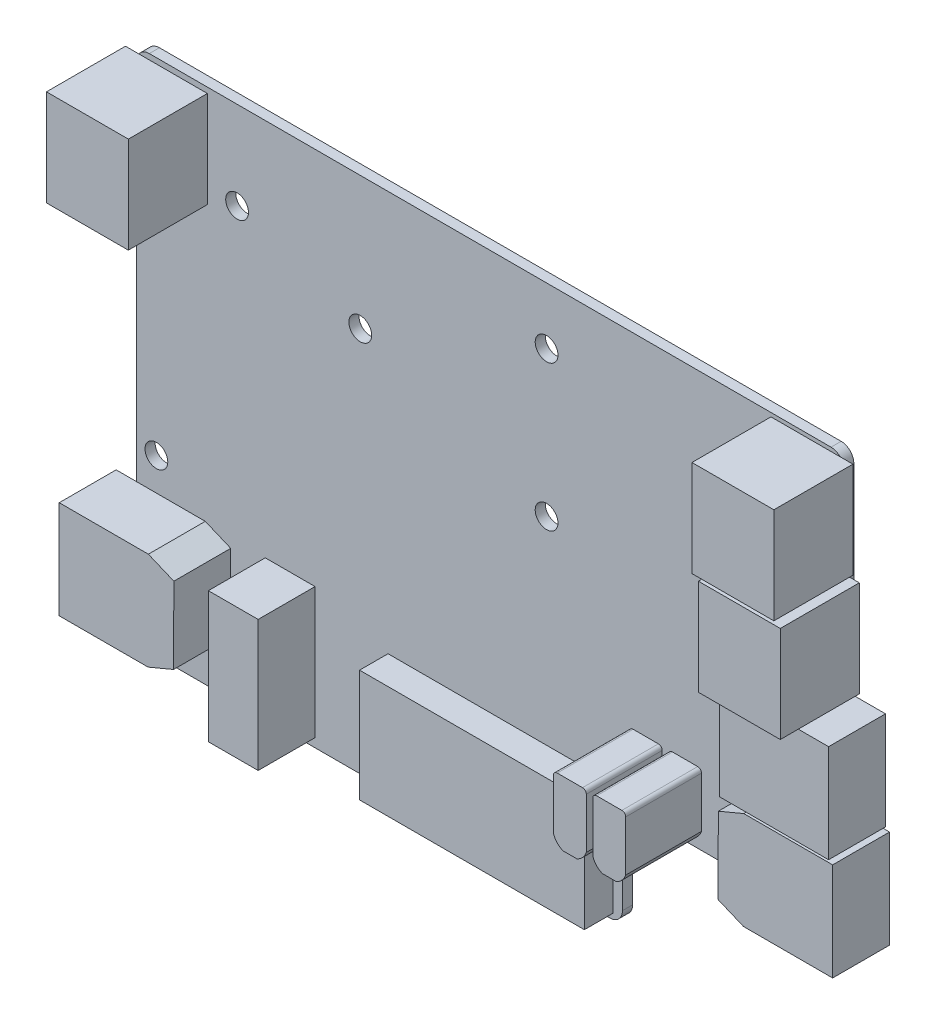
from build123d import *

# Parameters (mm, degrees)
SKETCH12_R          = 1.8
BOSS_EXTRUDE1_DEPTH = 1.6
SKETCH13_W          = 12.956032512
SKETCH13_H          = 15.22004064
BOSS_EXTRUDE2_DEPTH = 12.5
SKETCH14_W          = 35.56007112
SKETCH14_H          = 17.78003556
BOSS_EXTRUDE3_DEPTH = 4.5
SKETCH15_W          = 7.874015748
SKETCH15_H          = 20.701041402
BOSS_EXTRUDE4_DEPTH = 9
SKETCH16_W          = 17.272034544
SKETCH16_H          = 15.494030988
BOSS_EXTRUDE5_DEPTH = 9
BOSS_EXTRUDE6_DEPTH = 12


with BuildPart() as part:
    # Sketch12 → Boss-Extrude1 (new body)
    with BuildSketch(Plane.XY):
        with BuildLine():
            Line((62.461391923, 42.638430277), (-45.381305563, 42.638430277))
            ThreePointArc((-45.381305563, 42.638430277), (-46.795519125, 42.052643839), (-47.381305563, 40.638430277))
            Line((-47.381305563, 40.638430277), (-47.381305563, -37.360706121))
            ThreePointArc((-47.381305563, -37.360706121), (-46.795519125, -38.774919684), (-45.381305563, -39.360706121))
            Line((-45.381305563, -39.360706121), (27.461417323, -39.360706121))
            ThreePointArc((27.461417323, -39.360706121), (28.875325643, -38.775225046), (29.461417323, -37.361569723))
            Line((29.461417323, -37.361569723), (29.461417323, -24.861595123))
            ThreePointArc((29.461417323, -24.861595123), (30.04720376, -23.447381561), (31.461417323, -22.861595123))
            Line((31.461417323, -22.861595123), (62.461391923, -22.861595123))
            ThreePointArc((62.461391923, -22.861595123), (63.875614466, -22.275799705), (64.461391923, -20.861569723))
            Line((64.461391923, -20.861569723), (64.461391923, 40.638404877))
            ThreePointArc((64.461391923, 40.638404877), (63.875614466, 42.052634859), (62.461391923, 42.638430277))
        make_face()
        with Locations((-44.262382525, -36.110490221)):
            Circle(SKETCH12_R, mode=Mode.SUBTRACT)
        with Locations((-44.262382525, -11.860553721)):
            Circle(SKETCH12_R, mode=Mode.SUBTRACT)
        with Locations((17.461518923, 10.638303277)):
            Circle(SKETCH12_R, mode=Mode.SUBTRACT)
        with Locations((49.011938024, -19.421640843)):
            Circle(SKETCH12_R, mode=Mode.SUBTRACT)
        with Locations((49.011938024, 26.552451105)):
            Circle(SKETCH12_R, mode=Mode.SUBTRACT)
        with Locations((17.461518923, 33.638303277)):
            Circle(SKETCH12_R, mode=Mode.SUBTRACT)
        with Locations((-12.011684023, 21.638303277)):
            Circle(SKETCH12_R, mode=Mode.SUBTRACT)
        with Locations((-31.496062992, 28.703073406)):
            Circle(SKETCH12_R, mode=Mode.SUBTRACT)
        with Locations((-44.262382525, 21.639319279)):
            Circle(SKETCH12_R, mode=Mode.SUBTRACT)
    extrude(amount=BOSS_EXTRUDE1_DEPTH)

    # Sketch13 → Boss-Extrude2 (add)
    with BuildSketch(Plane.XY.offset(1.6)):
        with Locations((-42.673063246, 34.153073406)):
            Rectangle(SKETCH13_W, SKETCH13_H)
        with Locations((59.437096774, 34.427063754)):
            Rectangle(SKETCH13_W, SKETCH13_H)
        with Locations((60.453098806, 18.679032258)):
            Rectangle(SKETCH13_W, SKETCH13_H)
    extrude(amount=BOSS_EXTRUDE2_DEPTH)

    # Sketch14 → Boss-Extrude3 (add)
    with BuildSketch(Plane.XY.offset(1.6)):
        with Locations((10.16002032, -29.591059182)):
            Rectangle(SKETCH14_W, SKETCH14_H)
    extrude(amount=BOSS_EXTRUDE3_DEPTH)

    # Sketch15 → Boss-Extrude4 (add)
    with BuildSketch(Plane.XY.offset(1.6)):
        with Locations((-23.103886208, -27.622555245)):
            Rectangle(SKETCH15_W, SKETCH15_H)
    extrude(amount=BOSS_EXTRUDE4_DEPTH)

    # Sketch16 → Boss-Extrude5 (add)
    with BuildSketch(Plane.XY.offset(1.6)):
        Polygon((-50.630607061, -17.01516383), (-36.528168656, -17.018135636), (-32.500127, -18.703175006), (-32.548133096, -30.827127254), (-36.576174752, -32.512166624), (-50.630607061, -32.51513843), align=None)
        Polygon((71.712649225, -5.457937516), (71.712649225, -20.957912116), (57.61021082, -20.95494031), (53.582169164, -19.26990094), (53.63017526, -7.145948692), (57.658216916, -5.460909322), align=None)
        with Locations((62.436093472, 2.666954534)):
            Rectangle(SKETCH16_W, SKETCH16_H)
    extrude(amount=BOSS_EXTRUDE5_DEPTH)

    # Sketch17 → Boss-Extrude6 (add)
    with BuildSketch(Plane.XY.offset(1.6)):
        with BuildLine():
            Line((30.547345695, -12.263601727), (30.547345695, -20.239014478))
            ThreePointArc((30.547345695, -20.239014478), (31.126870936, -21.208709399), (32.047345695, -21.863601727))
            Line((32.047345695, -21.863601727), (34.247396495, -21.863601727))
            ThreePointArc((34.247396495, -21.863601727), (35.167885405, -21.208713404), (35.747421895, -20.239014478))
            Line((35.747421895, -20.239014478), (35.747421895, -12.263601727))
            ThreePointArc((35.747421895, -12.263601727), (35.571685964, -11.839312258), (35.147396495, -11.663576327))
            Line((35.147396495, -11.663576327), (31.147371095, -11.663576327))
            ThreePointArc((31.147371095, -11.663576327), (30.723081625, -11.839312258), (30.547345695, -12.263601727))
        make_face()
        with BuildLine():
            Line((36.770358141, -12.263601727), (36.770358141, -20.239014478))
            ThreePointArc((36.770358141, -20.239014478), (37.349883382, -21.208709399), (38.270358141, -21.863601727))
            Line((38.270358141, -21.863601727), (40.470408941, -21.863601727))
            ThreePointArc((40.470408941, -21.863601727), (41.390897851, -21.208713404), (41.970434341, -20.239014478))
            Line((41.970434341, -20.239014478), (41.970434341, -12.263601727))
            ThreePointArc((41.970434341, -12.263601727), (41.79469841, -11.839312258), (41.370408941, -11.663576327))
            Line((41.370408941, -11.663576327), (37.370383541, -11.663576327))
            ThreePointArc((37.370383541, -11.663576327), (36.946094071, -11.839312258), (36.770358141, -12.263601727))
        make_face()
    extrude(amount=BOSS_EXTRUDE6_DEPTH)


solid = part.part
